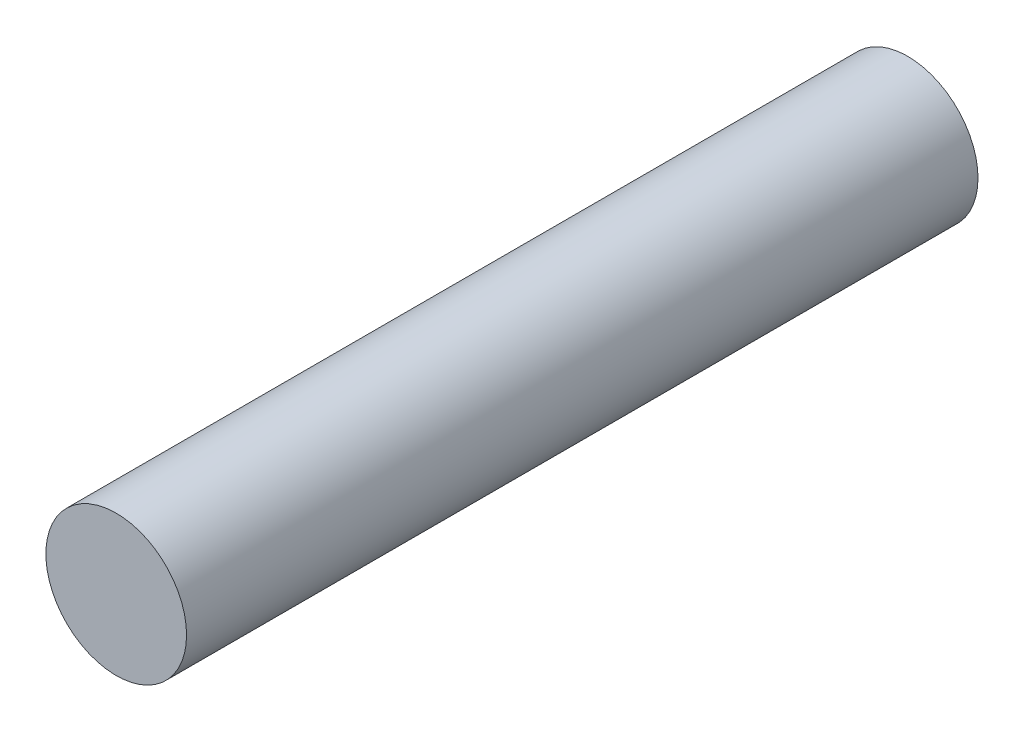
from build123d import *

# Parameters (mm, degrees)
SKETCH1_R           = 4
BOSS_EXTRUDE1_DEPTH = 45


with BuildPart() as part:
    # Sketch1 → Boss-Extrude1 (new body)
    with BuildSketch(Plane.XY):
        Circle(SKETCH1_R)
    extrude(amount=BOSS_EXTRUDE1_DEPTH)


solid = part.part
